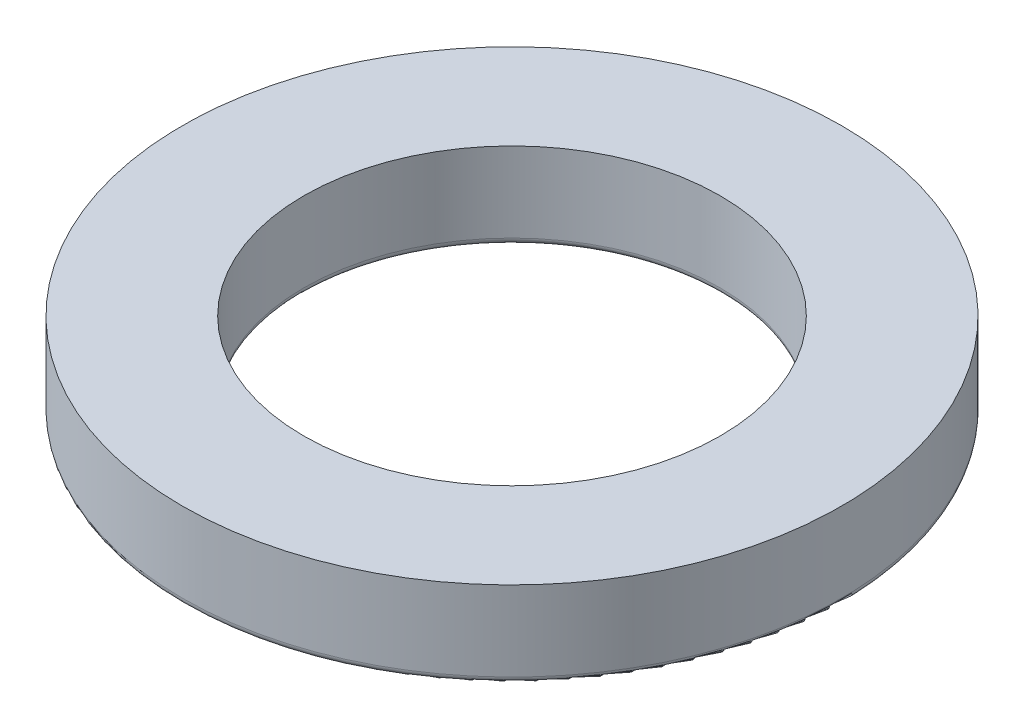
from build123d import *

# Parameters (mm, degrees)
SKETCH1_R           = 9.5
SKETCH1_R_2         = 6
BOSS_EXTRUDE1_DEPTH = 2.5
FILLET1_R           = 0.2


with BuildPart() as part:
    # Sketch1 → Boss-Extrude1 (new body)
    with BuildSketch(Plane(origin=(0, 0, 0), x_dir=(1, 0, 0), z_dir=(0, 1, 0))):
        Circle(SKETCH1_R)
        Circle(SKETCH1_R_2, mode=Mode.SUBTRACT)
    extrude(amount=BOSS_EXTRUDE1_DEPTH)

    # Fillet1
    fillet1_edges = [part.edges().sort_by_distance(p)[0] for p in [
        (-9.5, 0, 0),
        (-6, 0, 0),
    ]]
    fillet(fillet1_edges, radius=FILLET1_R)


solid = part.part
